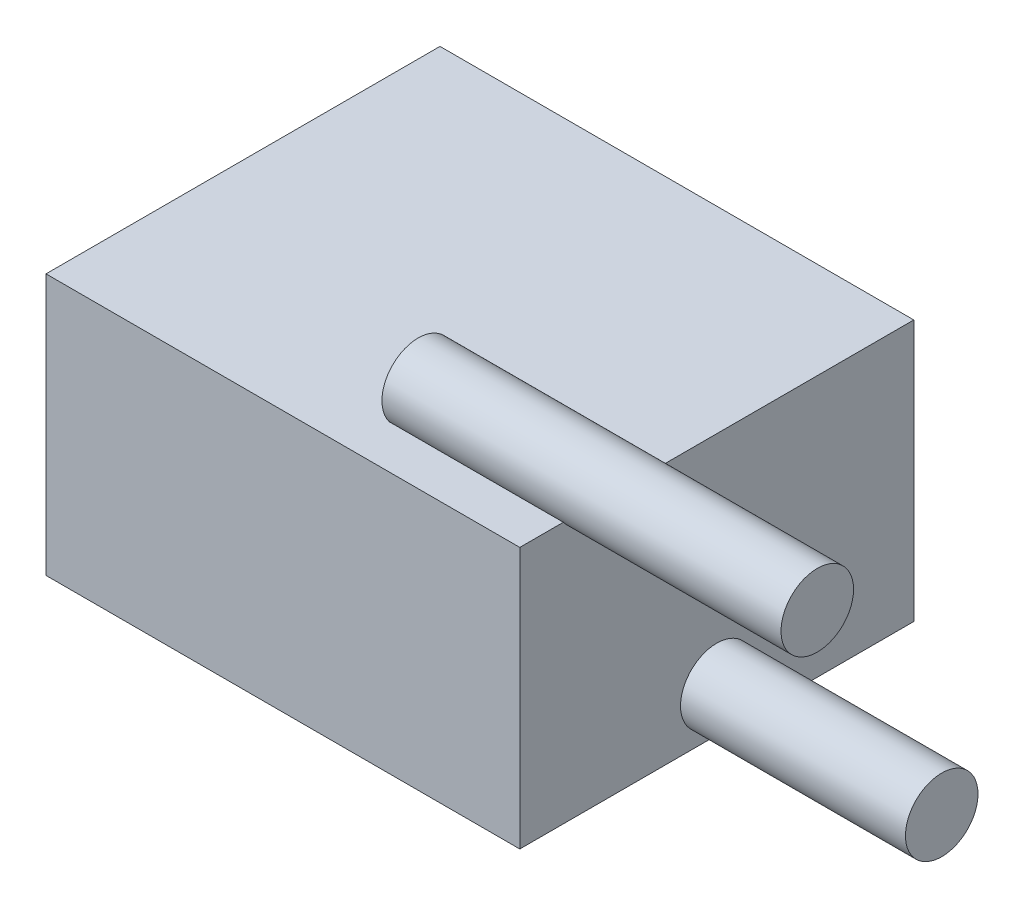
from build123d import *

# Parameters (mm, degrees)
SKETCH1_W                = 16.5862
SKETCH1_H                = 13.7922
BOSS_EXTRUDE1_DEPTH      = 9.144
SKETCH2_R                = 1.27
BOSS_EXTRUDE2_DEPTH      = 7.874
BOSS_EXTRUDE2_DEPTH_BACK = 6.096


with BuildPart() as part:
    # Sketch1 → Boss-Extrude1 (new body)
    with BuildSketch(Plane(origin=(0, 0, 0), x_dir=(1, 0, 0), z_dir=(0, 1, 0))):
        Rectangle(SKETCH1_W, SKETCH1_H)
    extrude(amount=BOSS_EXTRUDE1_DEPTH)

    # Sketch2 → Boss-Extrude2 (add, two sides)
    with BuildSketch(Plane(origin=(8.2931, 0, 0), x_dir=(0, 0, -1), z_dir=(1, 0, 0))) as boss_extrude2_sk:
        with Locations((0, 1.524)):
            Circle(SKETCH2_R)
        with Locations((-4.3561, 9.906)):
            Circle(SKETCH2_R)
    extrude(amount=BOSS_EXTRUDE2_DEPTH)
    extrude(boss_extrude2_sk.sketch, amount=-BOSS_EXTRUDE2_DEPTH_BACK)


solid = part.part
